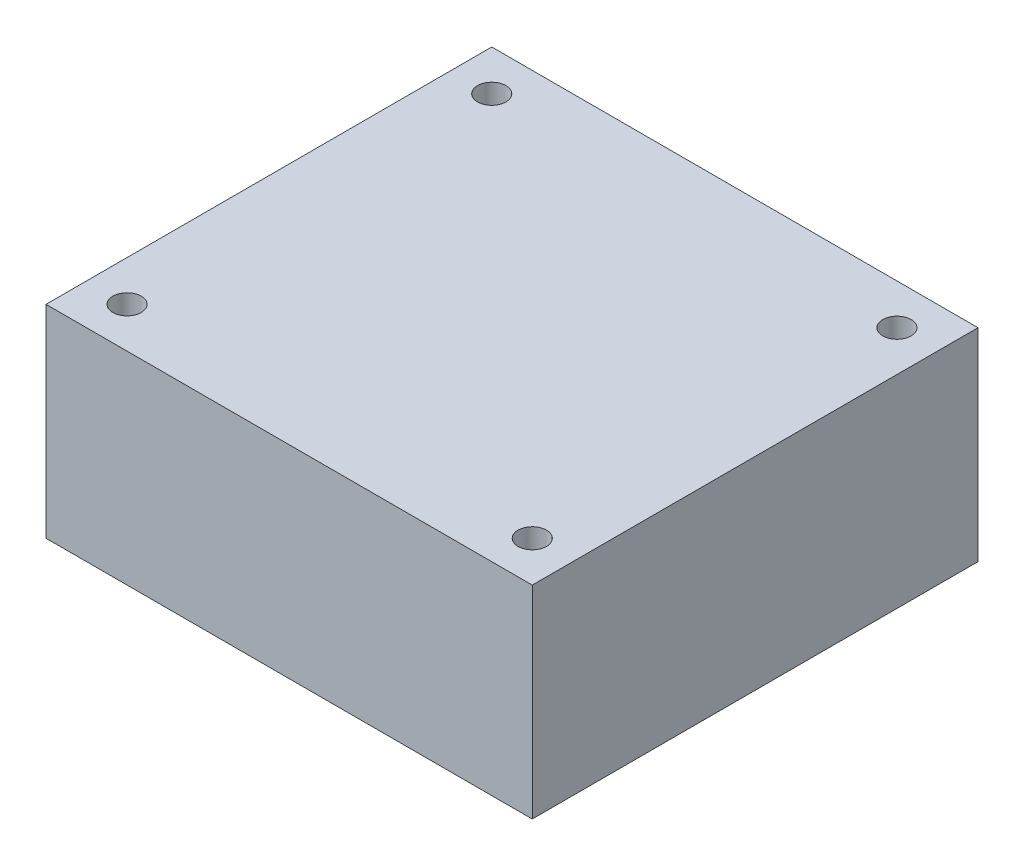
from build123d import *

# Parameters (mm, degrees)
SKETCH1_W           = 60
SKETCH1_H           = 55
BOSS_EXTRUDE1_DEPTH = 25
SKETCH2_R           = 1.75
CUT_EXTRUDE1_DEPTH  = 26


with BuildPart() as part:
    # Sketch1 → Boss-Extrude1 (new body)
    with BuildSketch(Plane(origin=(0, 0, 0), x_dir=(1, 0, 0), z_dir=(0, 1, 0))):
        with Locations((-8, -11.226027397)):
            Rectangle(SKETCH1_W, SKETCH1_H)
    extrude(amount=BOSS_EXTRUDE1_DEPTH)

    # Sketch2 → Cut-Extrude1 (cut, through all)
    with BuildSketch(Plane(origin=(0, 25, 0), x_dir=(1, 0, 0), z_dir=(0, 1, 0))):
        with Locations((-33, 11.273972603)):
            Circle(SKETCH2_R)
        with Locations((17, 11.273972603)):
            Circle(SKETCH2_R)
        with Locations((17, -33.726027397)):
            Circle(SKETCH2_R)
        with Locations((-33, -33.726027397)):
            Circle(SKETCH2_R)
    extrude(amount=-CUT_EXTRUDE1_DEPTH, mode=Mode.SUBTRACT)


solid = part.part
